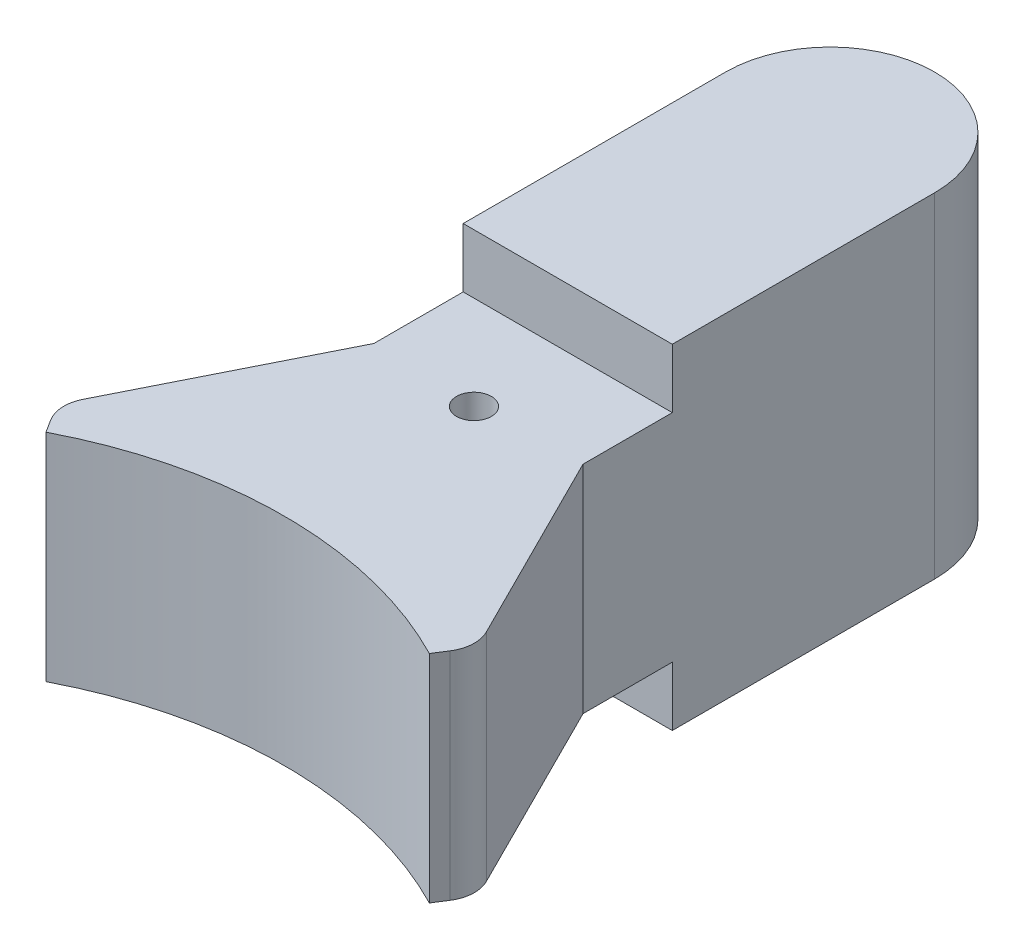
from build123d import *

# Parameters (mm, degrees)
SKETCH1_R               = 0.5
BOSS_EXTRUDE1_DEPTH     = 4.8
SKETCH3_W               = 11.720240581
SKETCH3_H               = 3.048700617
SKETCH3_W_2             = 11.288820682
SKETCH3_H_2             = 3.839637098
CUT_EXTRUDE1_DEPTH      = 6.889299393
CUT_EXTRUDE1_DEPTH_BACK = 6.889299393


with BuildPart() as part:
    # Sketch1 → Boss-Extrude1 (new body, symmetric)
    with BuildSketch(Plane(origin=(0, 0, 0), x_dir=(1, 0, 0), z_dir=(0, 1, 0))):
        with BuildLine():
            Line((-3, 9), (-3, -1.091261391))
            Line((-3, -1.091261391), (-5.78345363, -6.64968985))
            ThreePointArc((-5.78345363, -6.64968985), (-5.88797422, -7.148913405), (-5.732690839, -7.634748546))
            Line((-5.732690839, -7.634748546), (-5.5, -8))
            ThreePointArc((-5.5, -8), (0, -6.665364504), (5.5, -8))
            Line((5.5, -8), (5.732690839, -7.634748546))
            ThreePointArc((5.732690839, -7.634748546), (5.88797422, -7.148913405), (5.78345363, -6.64968985))
            Line((5.78345363, -6.64968985), (3, -1.091261391))
            Line((3, -1.091261391), (3, 9))
            ThreePointArc((3, 9), (0, 12), (-3, 9))
        make_face()
        with Locations((0, -1.22)):
            Circle(SKETCH1_R, mode=Mode.SUBTRACT)
    extrude(amount=BOSS_EXTRUDE1_DEPTH, both=True)

    # Sketch3 → Cut-Extrude1 (cut, two sides)
    with BuildSketch(Plane(origin=(0, 0, 0), x_dir=(0, 0, -1), z_dir=(1, 0, 0))) as cut_extrude1_sk:
        with Locations((-4.389443778, 4.624350309)):
            Rectangle(SKETCH3_W, SKETCH3_H)
        with Locations((-4.173733829, -5.019818549)):
            Rectangle(SKETCH3_W_2, SKETCH3_H_2)
    extrude(amount=CUT_EXTRUDE1_DEPTH, mode=Mode.SUBTRACT)
    extrude(cut_extrude1_sk.sketch, amount=-CUT_EXTRUDE1_DEPTH_BACK, mode=Mode.SUBTRACT)


solid = part.part
